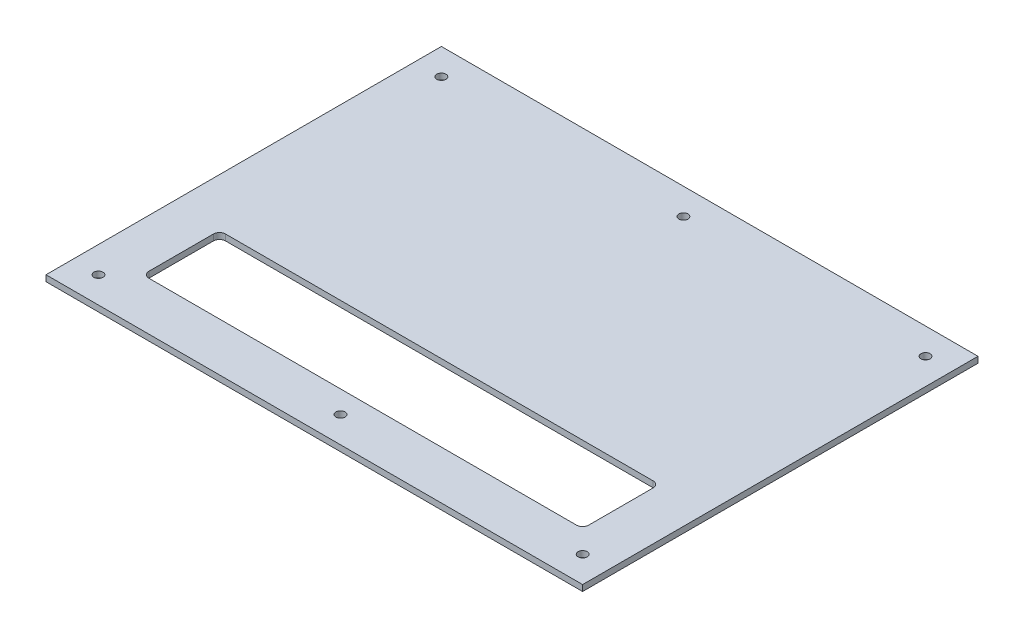
from build123d import *

# Parameters (mm, degrees)
SKETCH_1_W         = 266
SKETCH_1_H         = 196
SKETCH_1_R         = 2.25
EXTRUDE_1_DEPTH    = 3
SKETCH1_W          = 218
SKETCH1_H          = 38
CUT_EXTRUDE1_DEPTH = 4
FILLET1_R          = 3


with BuildPart() as part:
    # Эскиз1 → Бобышка-Вытянуть1 (new body)
    with BuildSketch(Plane(origin=(0, 0, 0), x_dir=(1, 0, 0), z_dir=(0, 1, 0))):
        with Locations((133, 98)):
            Rectangle(SKETCH_1_W, SKETCH_1_H)
        with Locations((13, 183)):
            Circle(SKETCH_1_R, mode=Mode.SUBTRACT)
        with Locations((253, 183)):
            Circle(SKETCH_1_R, mode=Mode.SUBTRACT)
        with Locations((253, 13)):
            Circle(SKETCH_1_R, mode=Mode.SUBTRACT)
        with Locations((13, 13)):
            Circle(SKETCH_1_R, mode=Mode.SUBTRACT)
        with Locations((133, 13)):
            Circle(SKETCH_1_R, mode=Mode.SUBTRACT)
        with Locations((133, 183)):
            Circle(SKETCH_1_R, mode=Mode.SUBTRACT)
    extrude(amount=EXTRUDE_1_DEPTH)

    # Sketch1 → Cut-Extrude1 (cut, through all)
    with BuildSketch(Plane.XZ):
        with Locations((133, -43)):
            Rectangle(SKETCH1_W, SKETCH1_H)
    extrude(amount=-CUT_EXTRUDE1_DEPTH, mode=Mode.SUBTRACT)

    # Fillet1
    fillet1_edges = [part.edges().sort_by_distance(p)[0] for p in [
        (24, 1.5, -62),
        (24, 1.5, -24),
        (242, 1.5, -24),
        (242, 1.5, -62),
    ]]
    fillet(fillet1_edges, radius=FILLET1_R)


solid = part.part
